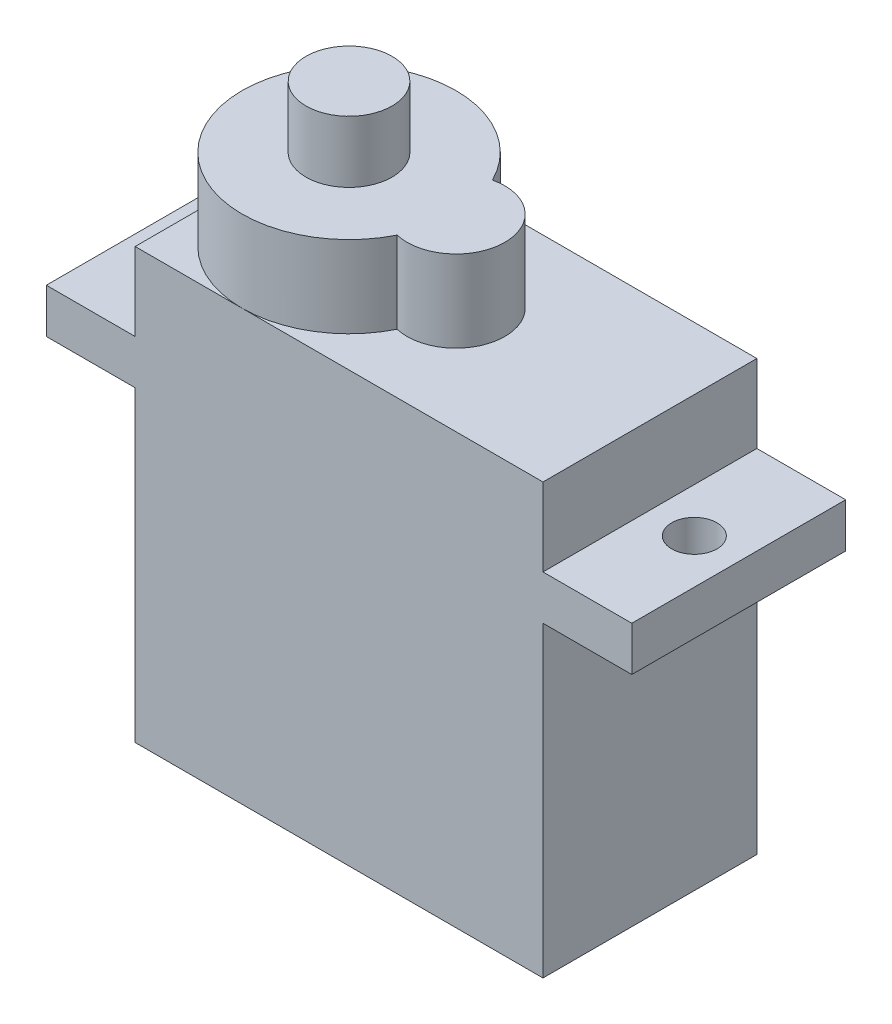
from build123d import *

# Parameters (mm, degrees)
BOSS_EXTRUDE1_DEPTH = 11.8
BOSS_EXTRUDE2_DEPTH = 4.5
SKETCH3_R           = 2.375
BOSS_EXTRUDE3_DEPTH = 3.4
CUT_EXTRUDE1_REACH  = 21.4
SKETCH4_R           = 1.25


with BuildPart() as part:
    # Sketch1 → Boss-Extrude1 (new body)
    with BuildSketch(Plane.XY):
        Polygon((0, 0), (22.5, 0), (22.5, 16.95), (27.4, 16.95), (27.4, 19.4), (22.5, 19.4), (22.5, 23.7), (0, 23.7), (0, 19.4), (-4.9, 19.4), (-4.9, 16.95), (0, 16.95), align=None)
    extrude(amount=BOSS_EXTRUDE1_DEPTH)

    # Sketch2 → Boss-Extrude2 (add)
    with BuildSketch(Plane(origin=(0, 23.7, 0), x_dir=(1, 0, 0), z_dir=(0, 1, 0))):
        with BuildLine():
            ThreePointArc((11.18220339, -3.271630287), (0, -5.9), (11.18220339, -8.528369713))
            ThreePointArc((11.18220339, -8.528369713), (14.5, -5.9), (11.18220339, -3.271630287))
        make_face()
    extrude(amount=BOSS_EXTRUDE2_DEPTH)

    # Sketch3 → Boss-Extrude3 (add)
    with BuildSketch(Plane(origin=(0, 28.2, 0), x_dir=(1, 0, 0), z_dir=(0, 1, 0))):
        with Locations((5.9, -5.9)):
            Circle(SKETCH3_R)
    extrude(amount=BOSS_EXTRUDE3_DEPTH)

    # Sketch4 → Cut-Extrude1 (cut, up to next)
    with BuildSketch(Plane(origin=(0, 19.4, 0), x_dir=(1, 0, 0), z_dir=(0, 1, 0)), mode=Mode.PRIVATE) as cut_extrude1_sk1:
        with Locations((-2.45, -5.9)):
            Circle(SKETCH4_R)
    cut_extrude1_tool1 = extrude(cut_extrude1_sk1.sketch, amount=-CUT_EXTRUDE1_REACH, mode=Mode.PRIVATE) & part.part
    add(cut_extrude1_tool1.solids().sort_by_distance((-2.45, 19.4, 5.9))[0], mode=Mode.SUBTRACT)
    # Sketch4 → Cut-Extrude1 (cut, up to next)
    with BuildSketch(Plane(origin=(0, 19.4, 0), x_dir=(1, 0, 0), z_dir=(0, 1, 0)), mode=Mode.PRIVATE) as cut_extrude1_sk2:
        with Locations((24.95, -5.9)):
            Circle(SKETCH4_R)
    cut_extrude1_tool2 = extrude(cut_extrude1_sk2.sketch, amount=-CUT_EXTRUDE1_REACH, mode=Mode.PRIVATE) & part.part
    add(cut_extrude1_tool2.solids().sort_by_distance((24.95, 19.4, 5.9))[0], mode=Mode.SUBTRACT)


solid = part.part
